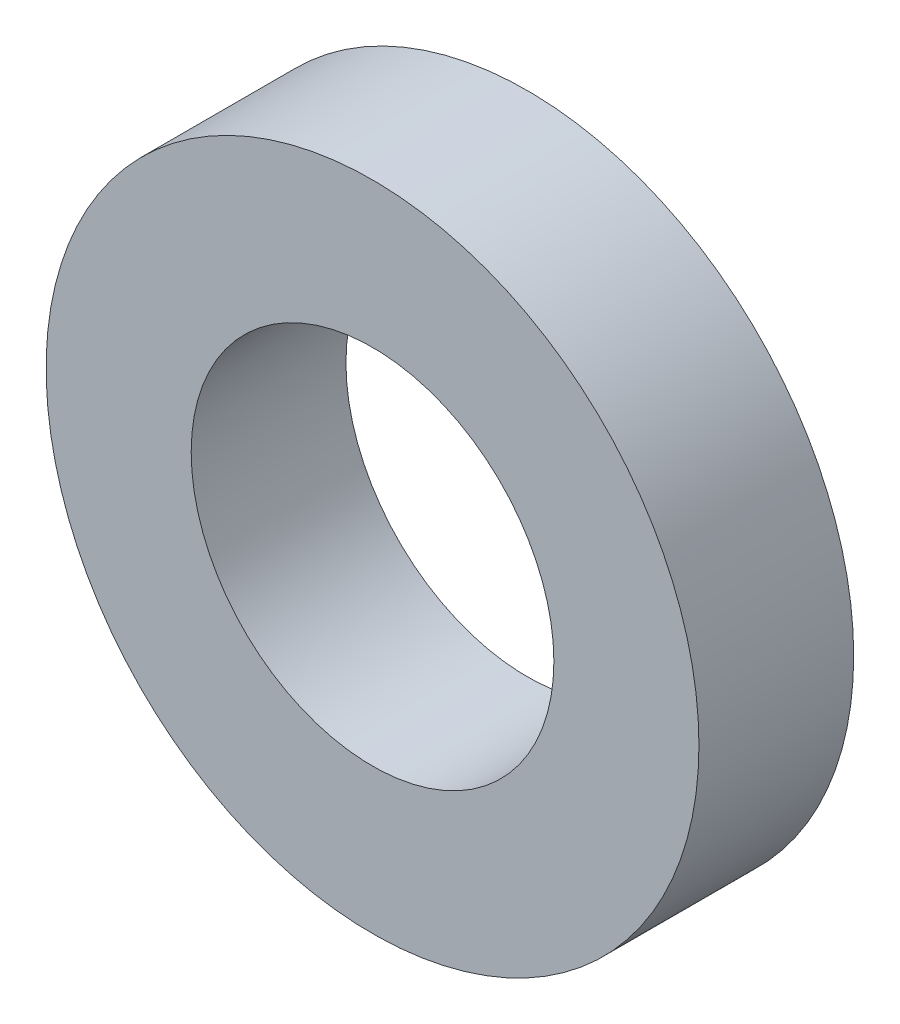
from build123d import *

# Parameters (mm, degrees)
CROQUIS1_R              = 6.75
CROQUIS1_R_2            = 3.75
SALIENTE_EXTRUIR1_DEPTH = 3.2


with BuildPart() as part:
    # Croquis1 → Saliente-Extruir1 (new body)
    with BuildSketch(Plane.XY):
        Circle(CROQUIS1_R)
        Circle(CROQUIS1_R_2, mode=Mode.SUBTRACT)
    extrude(amount=SALIENTE_EXTRUIR1_DEPTH)


solid = part.part
